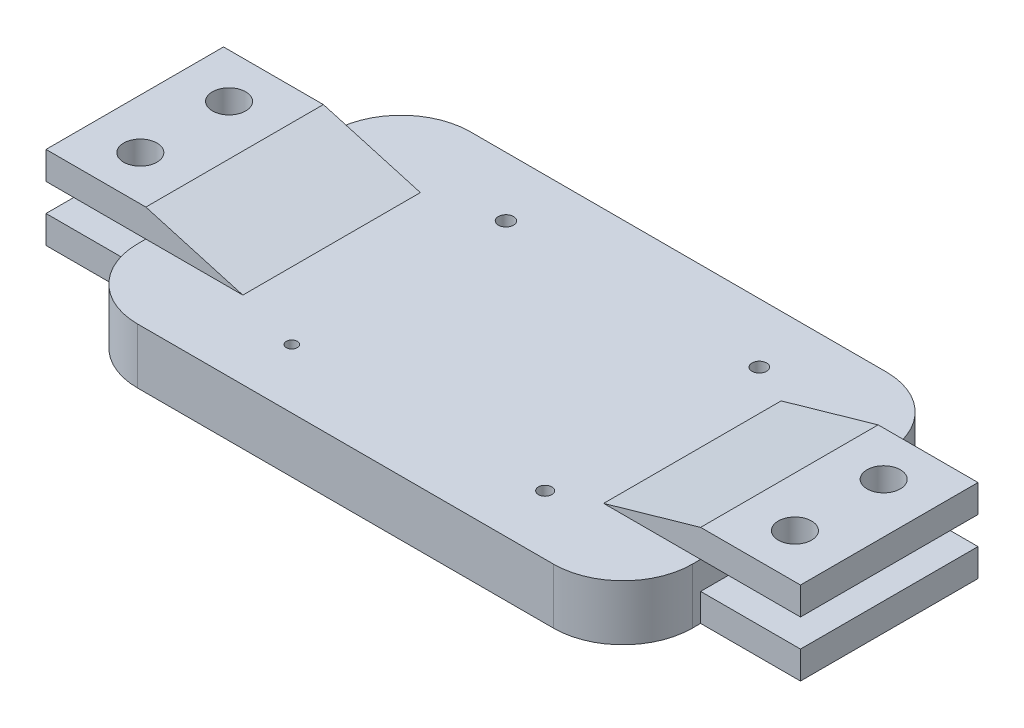
from build123d import *

# Parameters (mm, degrees)
SKETCH1_W             = 127
SKETCH1_H             = 76.2
BOSS_EXTRUDE1_DEPTH   = 12.7
SKETCH20_W            = 40.64
SKETCH20_H            = 6.35
BOSS_EXTRUDE7_DEPTH   = 22.86
BOSS_EXTRUDE7_2_DEPTH = 22.86
SKETCH21_R            = 3.81
CUT_EXTRUDE17_DEPTH   = 19.05
BOSS_EXTRUDE8_DEPTH   = 20.32
SKETCH19_R            = 1.671154259
SKETCH19_R_2          = 1.733603543
SKETCH19_R_3          = 1.269040072
SKETCH19_R_4          = 1.545344409
CUT_EXTRUDE18_DEPTH   = 42.672
CUT_EXTRUDE19_DEPTH   = 42.672


with BuildPart() as part:
    # Sketch1 → Boss-Extrude1 (new body)
    with BuildSketch(Plane(origin=(0, 0, 0), x_dir=(1, 0, 0), z_dir=(0, 1, 0))):
        Rectangle(SKETCH1_W, SKETCH1_H)
    extrude(amount=BOSS_EXTRUDE1_DEPTH)



with BuildPart() as body_2:
    # Sketch20 → Boss-Extrude7 (new body)
    with BuildSketch(Plane(origin=(63.5, 0, 0), x_dir=(0, 0, -1), z_dir=(1, 0, 0))):
        with Locations((0, 3.175)):
            Rectangle(SKETCH20_W, SKETCH20_H)
    boss_extrude7 = extrude(amount=BOSS_EXTRUDE7_DEPTH)


with BuildPart() as body_3:
    # Sketch20 → Boss-Extrude7 2 (new body)
    with BuildSketch(Plane(origin=(63.5, 0, 0), x_dir=(0, 0, -1), z_dir=(1, 0, 0))):
        with Locations((0, 15.875)):
            Rectangle(SKETCH20_W, SKETCH20_H)
    boss_extrude7_2 = extrude(amount=BOSS_EXTRUDE7_2_DEPTH)


with BuildPart() as cut_extrude17_tool:
    # Sketch21 → Cut-Extrude17 (new body)
    with BuildSketch(Plane(origin=(0, 19.05, 0), x_dir=(1, 0, 0), z_dir=(0, 1, 0))):
        with Locations((74.93, 10.16)):
            Circle(SKETCH21_R)
        with Locations((74.93, -10.16)):
            Circle(SKETCH21_R)
    cut_extrude17 = extrude(amount=-CUT_EXTRUDE17_DEPTH)


with BuildPart() as body_2_1:
    add(body_2.part)

    # Cut-Extrude17: cut by cut_extrude17_tool
    add(cut_extrude17_tool.part, mode=Mode.SUBTRACT)


with BuildPart() as body_3_1:
    add(body_3.part)

    # Cut-Extrude17: cut by cut_extrude17_tool
    add(cut_extrude17_tool.part, mode=Mode.SUBTRACT)


with BuildPart() as part_1:
    add(part.part)

    add(body_3_1.part)  # Boss-Extrude8 merges body 3
    # Sketch24 → Boss-Extrude8 (add, symmetric)
    with BuildSketch(Plane.XY):
        Polygon((63.5, 19.05), (41.29642666, 12.7), (63.5, 12.7), align=None)
    boss_extrude8 = extrude(amount=BOSS_EXTRUDE8_DEPTH, both=True)

    # Sketch19 → Cut-Extrude18 (cut)
    with BuildSketch(Plane(origin=(0, 0, 0), x_dir=(-1, 0, 0), z_dir=(0, -1, 0))):
        with Locations((-32.09925, 24.511)):
            Circle(SKETCH19_R)
        with Locations((25.90074068, 24.511)):
            Circle(SKETCH19_R_2)
        with Locations((25.90074068, -24.511)):
            Circle(SKETCH19_R_3)
        with Locations((-32.09925, -24.511)):
            Circle(SKETCH19_R_4)
    extrude(amount=-CUT_EXTRUDE18_DEPTH, mode=Mode.SUBTRACT)

    # Sketch12 → Cut-Extrude19 (cut)
    with BuildSketch(Plane(origin=(0, 12.7, 0), x_dir=(1, 0, 0), z_dir=(0, 1, 0))):
        with BuildLine():
            ThreePointArc((-47.625, -38.1), (-58.850320151, -33.450320151), (-63.5, -22.225))
            Line((-63.5, -22.225), (-63.5, -38.1))
            Line((-63.5, -38.1), (-47.625, -38.1))
        make_face()
        with BuildLine():
            ThreePointArc((-63.5, 22.225), (-58.850320151, 33.450320151), (-47.625, 38.1))
            Line((-47.625, 38.1), (-63.5, 38.1))
            Line((-63.5, 38.1), (-63.5, 22.225))
        make_face()
        with BuildLine():
            Line((63.5, 38.1), (47.625, 38.1))
            ThreePointArc((47.625, 38.1), (58.850320151, 33.450320151), (63.5, 22.225))
            Line((63.5, 22.225), (63.5, 38.1))
        make_face()
        with BuildLine():
            Line((63.5, -38.1), (63.5, -22.225))
            ThreePointArc((63.5, -22.225), (58.850320151, -33.450320151), (47.625, -38.1))
            Line((47.625, -38.1), (63.5, -38.1))
        make_face()
    extrude(amount=-CUT_EXTRUDE19_DEPTH, mode=Mode.SUBTRACT)

    # Mirror1: Boss-Extrude7, Boss-Extrude7 2, Cut-Extrude17, Boss-Extrude8 across plane
    add(boss_extrude7.mirror(Plane(origin=(0, 0, 0), x_dir=(0, 0, 1), z_dir=(1, 0, 0))))
    add(boss_extrude7_2.mirror(Plane(origin=(0, 0, 0), x_dir=(0, 0, 1), z_dir=(1, 0, 0))))
    add(cut_extrude17.mirror(Plane(origin=(0, 0, 0), x_dir=(0, 0, 1), z_dir=(1, 0, 0))), mode=Mode.SUBTRACT)
    add(boss_extrude8.mirror(Plane(origin=(0, 0, 0), x_dir=(0, 0, 1), z_dir=(1, 0, 0))))


solid = Compound([body_2_1.part, part_1.part])
